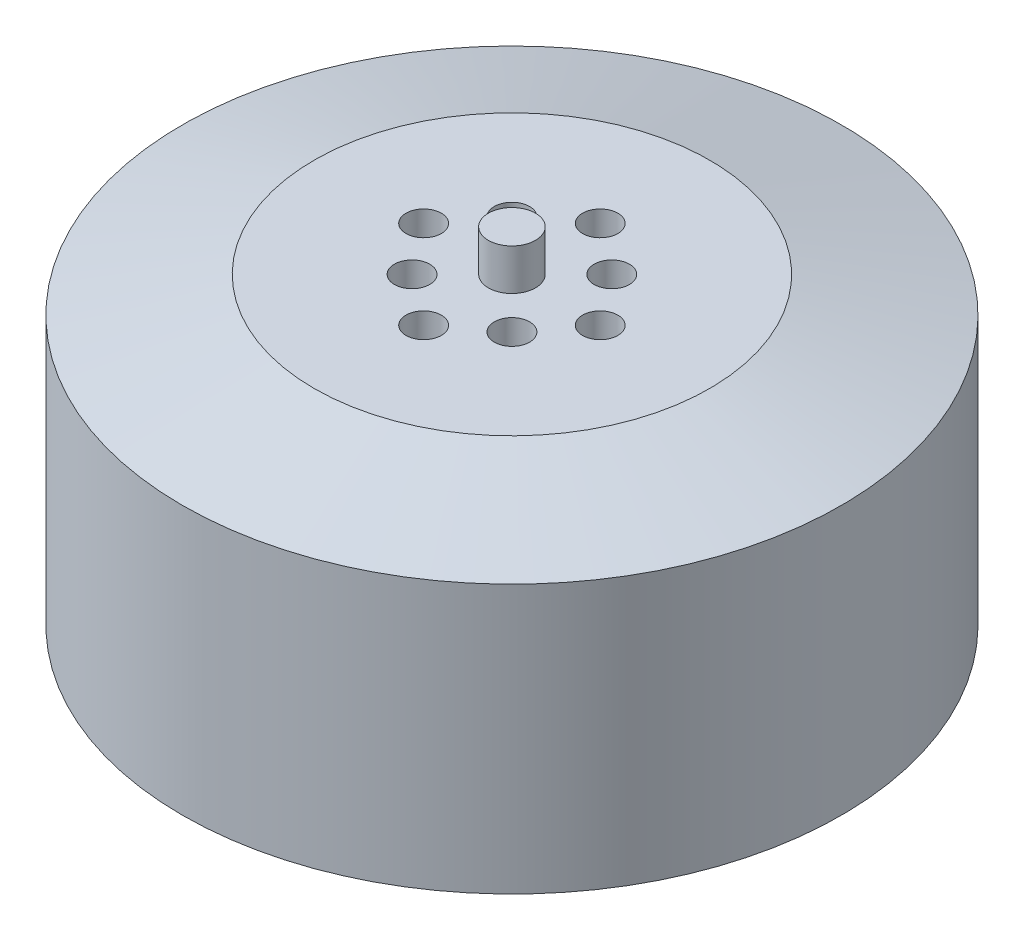
from build123d import *

# Parameters (mm, degrees)
SKETCH1_R           = 28
BOSS_EXTRUDE1_DEPTH = 25.8
SKETCH2_R           = 2
BOSS_EXTRUDE2_DEPTH = 3.5
SKETCH3_R           = 1.5
CUT_EXTRUDE1_DEPTH  = 3
SKETCH4_R           = 1.5
CUT_EXTRUDE2_DEPTH  = 3
CHAMFER1_SIZE       = 3
CHAMFER1_SIZE2      = 11.196152423


with BuildPart() as part:
    # Sketch1 → Boss-Extrude1 (new body)
    with BuildSketch(Plane(origin=(0, 0, 0), x_dir=(1, 0, 0), z_dir=(0, 1, 0))):
        Circle(SKETCH1_R)
    extrude(amount=BOSS_EXTRUDE1_DEPTH)

    # Sketch2 → Boss-Extrude2 (add)
    with BuildSketch(Plane(origin=(0, 25.8, 0), x_dir=(1, 0, 0), z_dir=(0, 1, 0))):
        Circle(SKETCH2_R)
    extrude(amount=BOSS_EXTRUDE2_DEPTH)

    # Sketch3 → Cut-Extrude1 (cut)
    with BuildSketch(Plane.XZ):
        with Locations((0, 15)):
            Circle(SKETCH3_R)
        with Locations((15, 0)):
            Circle(SKETCH3_R)
        with Locations((0, -15)):
            Circle(SKETCH3_R)
        with Locations((-15, 0)):
            Circle(SKETCH3_R)
    extrude(amount=-CUT_EXTRUDE1_DEPTH, mode=Mode.SUBTRACT)

    # Sketch4 → Cut-Extrude2 (cut)
    with BuildSketch(Plane(origin=(0, 25.8, 0), x_dir=(1, 0, 0), z_dir=(0, 1, 0))):
        with Locations((0, 7.5)):
            Circle(SKETCH4_R)
        with Locations((7.5, 0)):
            Circle(SKETCH4_R)
        with Locations((0, -7.5)):
            Circle(SKETCH4_R)
        with Locations((-7.5, 0)):
            Circle(SKETCH4_R)
        with Locations((4.242640687, 4.242640687)):
            Circle(SKETCH4_R)
        with Locations((4.242640687, -4.242640687)):
            Circle(SKETCH4_R)
        with Locations((-4.242640687, -4.242640687)):
            Circle(SKETCH4_R)
        with Locations((-4.242640687, 4.242640687)):
            Circle(SKETCH4_R)
    extrude(amount=-CUT_EXTRUDE2_DEPTH, mode=Mode.SUBTRACT)

    # Chamfer1
    chamfer1_edges = [part.edges().sort_by_distance(p)[0] for p in [
        (-28, 25.8, 0),
    ]]
    chamfer1_side = [part.faces().sort_by_distance(p)[0] for p in [
        (-28, 12.9, 0),
    ]]
    chamfer(chamfer1_edges, length=CHAMFER1_SIZE, length2=CHAMFER1_SIZE2, reference=chamfer1_side[0])


solid = part.part
